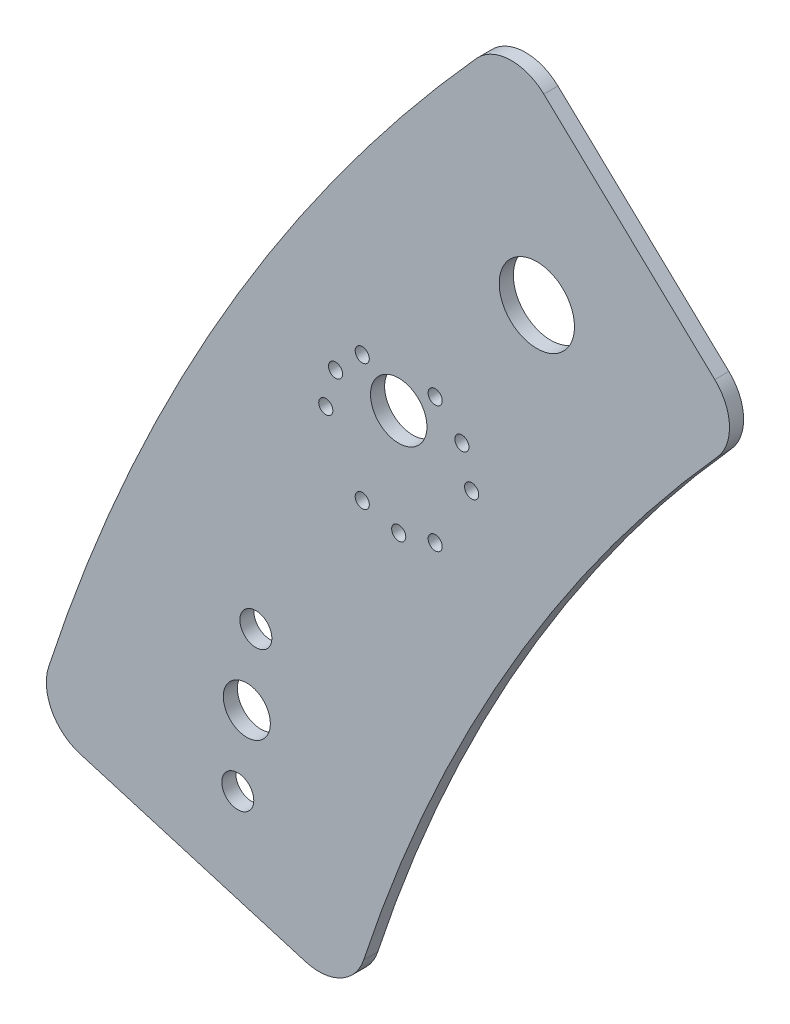
from build123d import *

# Parameters (mm, degrees)
SKETCH1_R           = 3.4
SKETCH1_R_2         = 5
SKETCH1_R_3         = 8
SKETCH1_R_4         = 1.5
SKETCH1_R_5         = 6
BOSS_EXTRUDE1_DEPTH = 3
SKETCH4_R           = 1.5
CUT_EXTRUDE1_DEPTH  = 3
CIRPATTERN1_COUNT   = 6


with BuildPart() as part:
    # Sketch1 → Boss-Extrude1 (new body)
    with BuildSketch(Plane.XY):
        with BuildLine():
            ThreePointArc((-271.800817077, 243.790124811), (-269.253440252, 250.876511464), (-272.371911597, 257.730790488))
            Line((-272.371911597, 257.730790488), (-308.701287129, 292.107311249))
            ThreePointArc((-308.701287129, 292.107311249), (-315.968083296, 294.835963731), (-322.997699137, 291.544099213))
            ThreePointArc((-322.997699137, 291.544099213), (-376.789694918, 217.612042952), (-413.944817586, 134.07148626))
            ThreePointArc((-413.944817586, 134.07148626), (-413.283077207, 126.337537039), (-407.288017737, 121.406904946))
            Line((-407.288017737, 121.406904946), (-359.356506069, 107.119186605))
            ThreePointArc((-359.356506069, 107.119186605), (-351.861081548, 107.843490223), (-346.996122098, 113.591374532))
            ThreePointArc((-346.996122098, 113.591374532), (-316.172961568, 182.603306357), (-271.800817077, 243.790124811))
        make_face()
        with Locations((-373.746213466, 131.27857223)):
            Circle(SKETCH1_R, mode=Mode.SUBTRACT)
        with Locations((-371.824242114, 147.162716089)):
            Circle(SKETCH1_R_2, mode=Mode.SUBTRACT)
        with Locations((-369.902270762, 163.046859947)):
            Circle(SKETCH1_R, mode=Mode.SUBTRACT)
        with Locations((-310.189407893, 252.536198061)):
            Circle(SKETCH1_R_3, mode=Mode.SUBTRACT)
        with Locations((-326.120312176, 219.178644843)):
            Circle(SKETCH1_R_4, mode=Mode.SUBTRACT)
        with Locations((-339.543705934, 195.928644843)):
            Circle(SKETCH1_R_4, mode=Mode.SUBTRACT)
        with Locations((-352.967099693, 219.178644843)):
            Circle(SKETCH1_R_4, mode=Mode.SUBTRACT)
        with Locations((-339.543705934, 218.428644843)):
            Circle(SKETCH1_R_5, mode=Mode.SUBTRACT)
    extrude(amount=BOSS_EXTRUDE1_DEPTH)

    # Sketch4 → Cut-Extrude1 (cut)
    with BuildSketch(Plane.XY.offset(3)):
        with Locations((-324.043705934, 211.428644843)):
            Circle(SKETCH4_R)
    cut_extrude1 = extrude(amount=-CUT_EXTRUDE1_DEPTH, mode=Mode.SUBTRACT)

    # CirPattern1: Cut-Extrude1 ×6 about axis
    cirpattern1_axis = Axis((-339.543705934, 211.428644843, 0), (0, 0, 1))
    for i in range(1, CIRPATTERN1_COUNT):
        add(cut_extrude1.rotate(cirpattern1_axis, i * 360 / CIRPATTERN1_COUNT), mode=Mode.SUBTRACT)


solid = part.part
